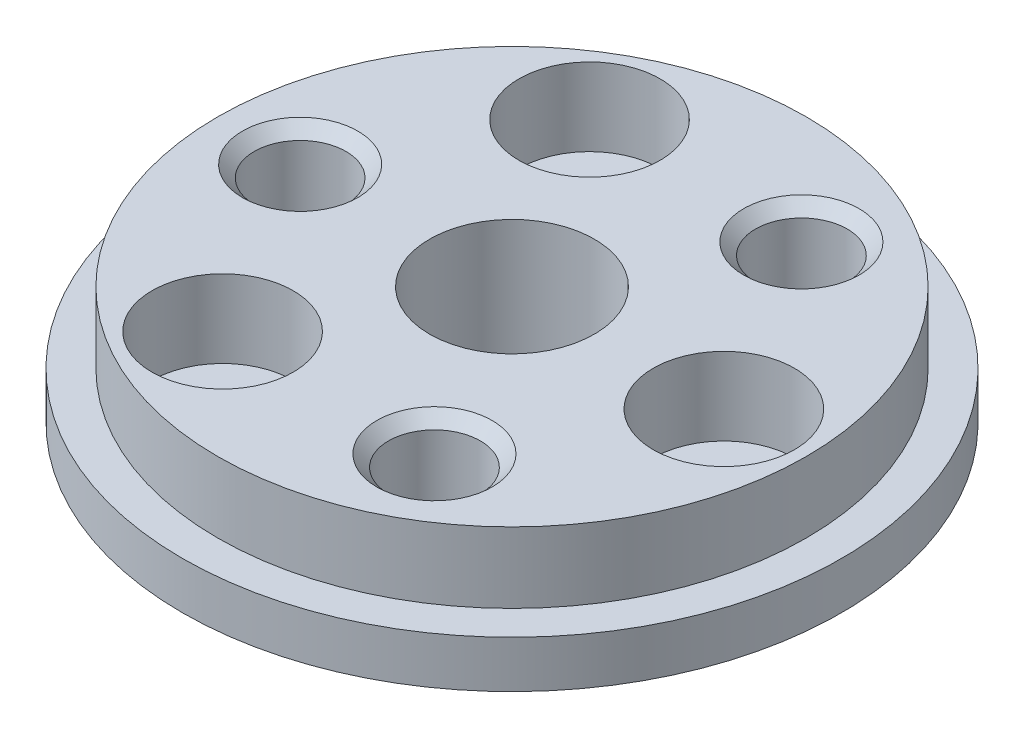
from build123d import *

# Parameters (mm, degrees)
SKETCH_1_R          = 14
EXTRUDE_1_DEPTH     = 2
SKETCH_2_R          = 12.5
EXTRUDE_2_DEPTH     = 3
SKETCH_3_R          = 1.6
CUT_EXTRUDE_1_DEPTH = 6
SKETCH_4_R          = 3
CUT_EXTRUDE_2_DEPTH = 3.3
SKETCH_5_R          = 1.95
CUT_EXTRUDE_3_DEPTH = 3.2
CHAMFER_1_SIZE      = 0.5
SKETCH_6_R          = 3.5
CUT_EXTRUDE_4_DEPTH = 6


with BuildPart() as part:
    # 草图1 → 凸台-拉伸1 (new body)
    with BuildSketch(Plane(origin=(0, 0, 0), x_dir=(1, 0, 0), z_dir=(0, 1, 0))):
        Circle(SKETCH_1_R)
    extrude(amount=EXTRUDE_1_DEPTH)

    # 草图2 → 凸台-拉伸2 (add)
    with BuildSketch(Plane(origin=(0, 2, 0), x_dir=(1, 0, 0), z_dir=(0, 1, 0))):
        Circle(SKETCH_2_R)
    extrude(amount=EXTRUDE_2_DEPTH)

    # 草图3 → 切除-拉伸1 (cut, through all)
    with BuildSketch(Plane(origin=(0, 5, 0), x_dir=(1, 0, 0), z_dir=(0, 1, 0))):
        with Locations((9, 0)):
            Circle(SKETCH_3_R)
        with Locations((-4.5, -7.794228634)):
            Circle(SKETCH_3_R)
        with Locations((-4.5, 7.794228634)):
            Circle(SKETCH_3_R)
    extrude(amount=-CUT_EXTRUDE_1_DEPTH, mode=Mode.SUBTRACT)

    # 草图4 → 切除-拉伸2 (cut)
    with BuildSketch(Plane(origin=(0, 5, 0), x_dir=(1, 0, 0), z_dir=(0, 1, 0))):
        with Locations((9, 0)):
            Circle(SKETCH_4_R)
        with Locations((-4.5, 7.794228634)):
            Circle(SKETCH_4_R)
        with Locations((-4.5, -7.794228634)):
            Circle(SKETCH_4_R)
    extrude(amount=-CUT_EXTRUDE_2_DEPTH, mode=Mode.SUBTRACT)

    # 草图5 → 切除-拉伸3 (cut)
    with BuildSketch(Plane(origin=(0, 5, 0), x_dir=(1, 0, 0), z_dir=(0, 1, 0))):
        with Locations((4.5, 7.794228634)):
            Circle(SKETCH_5_R)
        with Locations((4.5, -7.794228634)):
            Circle(SKETCH_5_R)
        with Locations((-9, 0)):
            Circle(SKETCH_5_R)
    extrude(amount=-CUT_EXTRUDE_3_DEPTH, mode=Mode.SUBTRACT)

    # 倒角1
    chamfer_1_edges = [part.edges().sort_by_distance(p)[0] for p in [
        (2.55, 5, -7.794228634),
        (2.55, 5, 7.794228634),
        (-10.95, 5, 0),
    ]]
    chamfer(chamfer_1_edges, length=CHAMFER_1_SIZE)

    # 草图6 → 切除-拉伸4 (cut, through all)
    with BuildSketch(Plane(origin=(0, 5, 0), x_dir=(1, 0, 0), z_dir=(0, 1, 0))):
        Circle(SKETCH_6_R)
    extrude(amount=-CUT_EXTRUDE_4_DEPTH, mode=Mode.SUBTRACT)


solid = part.part
